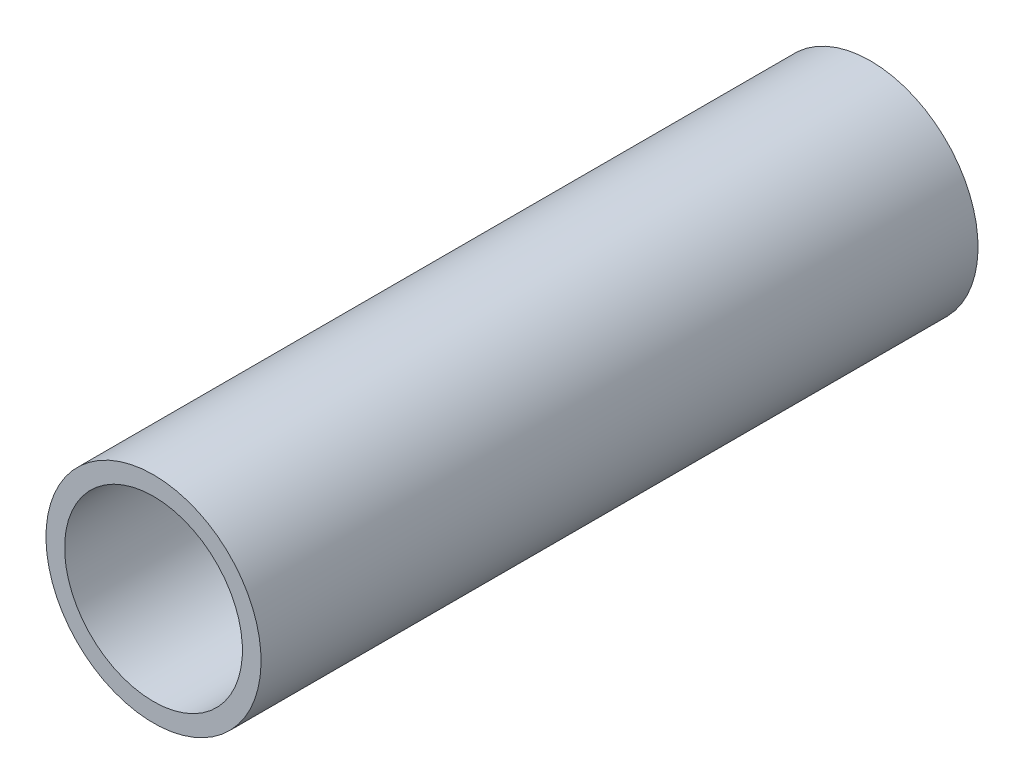
from build123d import *

# Parameters (mm, degrees)
SKETCH1_W = 63.5
SKETCH1_H = 1.651


with BuildPart() as part:
    # Sketch1 → Revolve1 (revolve)
    with BuildSketch(Plane(origin=(0, 0, 0), x_dir=(0, 0, -1), z_dir=(1, 0, 0))):
        with Locations((0, 8.6995)):
            Rectangle(SKETCH1_W, SKETCH1_H)
    revolve(axis=Axis((0, 0, 0), (0, 0, 1)))


solid = part.part
